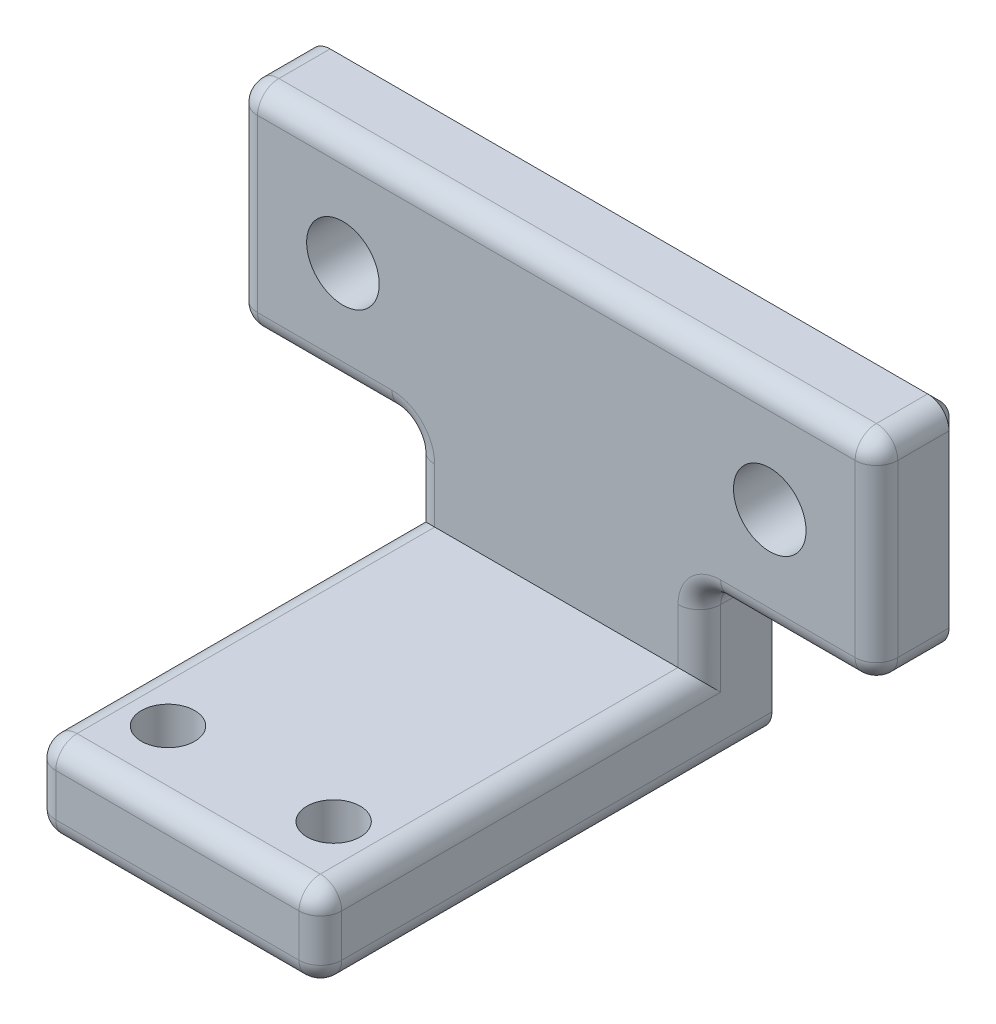
from build123d import *

# Parameters (mm, degrees)
SKETCH1_W           = 30
SKETCH1_H           = 10
SKETCH1_R           = 1.7
BOSS_EXTRUDE1_DEPTH = 4
BOSS_EXTRUDE2_START = -13.4
BOSS_EXTRUDE2_DEPTH = 13.4
SKETCH3_R           = 1.25
CUT_EXTRUDE1_DEPTH  = 2
FILLET1_R           = 1
CHAMFER1_SIZE       = 0.6


with BuildPart() as part:
    # Sketch1 → Boss-Extrude1 (new body)
    with BuildSketch(Plane.XY):
        with Locations((34.05, 0)):
            Rectangle(SKETCH1_W, SKETCH1_H)
        with Locations((44.05, 0)):
            Circle(SKETCH1_R, mode=Mode.SUBTRACT)
        with Locations((24.05, 0)):
            Circle(SKETCH1_R, mode=Mode.SUBTRACT)
    extrude(amount=BOSS_EXTRUDE1_DEPTH)

    # Sketch2 → Boss-Extrude2 (add)
    with BuildSketch(Plane.ZY.offset(-27.35).offset(BOSS_EXTRUDE2_START)):
        Polygon((21.756367983, -8.555), (4, -8.555), (4, -5), (0, -5), (0, -12.555), (21.756367983, -12.555), align=None)
    extrude(amount=BOSS_EXTRUDE2_DEPTH)

    # Sketch3 → Cut-Extrude1 (cut)
    with BuildSketch(Plane(origin=(0, -8.555, 0), x_dir=(1, 0, 0), z_dir=(0, 1, 0))):
        with Locations((30.17, -18.316367983)):
            Circle(SKETCH3_R)
        with Locations((37.93, -18.316367983)):
            Circle(SKETCH3_R)
    extrude(amount=-CUT_EXTRUDE1_DEPTH, mode=Mode.SUBTRACT)

    # Fillet1
    fillet1_edges = [part.edges().sort_by_distance(p)[0] for p in [
        (19.05, 0, 4),
        (23.2, -5, 4),
        (44.9, -5, 4),
        (34.05, -8.555, 21.756367983),
        (34.05, -12.555, 21.756367983),
        (27.35, -10.555, 21.756367983),
        (27.35, -8.555, 12.878183991),
        (27.35, -6.7775, 4),
        (27.35, -5, 2),
        (27.35, -12.555, 10.878183991),
        (40.75, -10.555, 21.756367983),
        (40.75, -12.555, 10.878183991),
        (40.75, -5, 2),
        (40.75, -6.7775, 4),
        (40.75, -8.555, 12.878183991),
        (49.05, 0, 4),
        (49.05, -5, 2),
        (19.05, -5, 2),
        (19.05, 5, 2),
        (49.05, 5, 2),
        (34.05, 5, 4),
    ]]
    fillet(fillet1_edges, radius=FILLET1_R)

    # Chamfer1
    chamfer1_edges = [part.edges().sort_by_distance(p)[0] for p in [
        (42.35, 0, 0),
        (22.35, 0, 0),
        (23.2, -5, 0),
        (40.75, -8.7775, 0),
        (19.05, 0, 0),
        (27.35, -8.7775, 0),
        (34.05, 5, 0),
        (49.05, 0, 0),
        (44.9, -5, 0),
        (34.05, -12.555, 0),
        (19.342893219, -4.707106781, 0),
        (19.342893219, 4.707106781, 0),
        (48.757106781, 4.707106781, 0),
        (48.757106781, -4.707106781, 0),
        (40.457106781, -12.262106781, 0),
        (27.642893219, -12.262106781, 0),
        (41.042893219, -5.292893219, 0),
        (27.057106781, -5.292893219, 0),
    ]]
    chamfer(chamfer1_edges, length=CHAMFER1_SIZE)


solid = part.part
